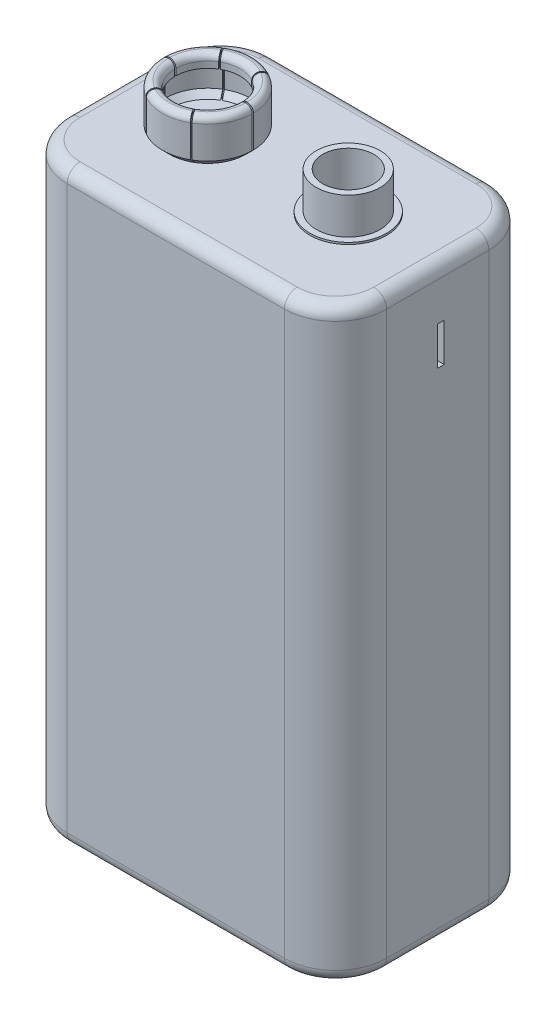
from build123d import *

# Parameters (mm, degrees)
SKETCH2_W           = 25
SKETCH2_H           = 16
BOSS_EXTRUDE1_DEPTH = 46
FILLET1_R           = 4
FILLET2_R           = 1
SKETCH3_R           = 2.5
SKETCH3_R_2         = 2
EXTRUDE_THIN1_DEPTH = 3
SKETCH6_R           = 1
BOSS_EXTRUDE2_DEPTH = 0.75
SKETCH10_W          = 1.5
SKETCH10_H          = 0.1
CUT_EXTRUDE1_DEPTH  = 4.375498081
CIRPATTERN1_COUNT   = 6
SKETCH11_R          = 3
BOSS_EXTRUDE3_DEPTH = 0.15
CUT_EXTRUDE2_DEPTH  = 1
SKETCH13_W          = 0.5
SKETCH13_H          = 3
CUT_EXTRUDE3_DEPTH  = 1


with BuildPart() as part:
    # Sketch2 → Boss-Extrude1 (new body)
    with BuildSketch(Plane(origin=(0, 0, 0), x_dir=(1, 0, 0), z_dir=(0, 1, 0))):
        Rectangle(SKETCH2_W, SKETCH2_H)
    extrude(amount=BOSS_EXTRUDE1_DEPTH)

    # Fillet1
    fillet1_edges = [part.edges().sort_by_distance(p)[0] for p in [
        (12.5, 23, 8),
        (-12.5, 23, 8),
        (-12.5, 23, -8),
        (12.5, 23, -8),
    ]]
    fillet(fillet1_edges, radius=FILLET1_R)

    # Fillet2
    fillet2_edges = [part.edges().sort_by_distance(p)[0] for p in [
        (-12.5, 0, 0),
        (-12.5, 46, 0),
        (12.5, 0, 0),
        (0, 0, 8),
        (0, 0, -8),
        (11.328427125, 0, 6.828427125),
        (11.328427125, 0, -6.828427125),
        (-11.328427125, 0, 6.828427125),
        (-11.328427125, 0, -6.828427125),
        (0, 46, -8),
        (12.5, 46, 0),
        (0, 46, 8),
        (11.328427125, 46, 6.828427125),
        (11.328427125, 46, -6.828427125),
        (-11.328427125, 46, 6.828427125),
        (-11.328427125, 46, -6.828427125),
    ]]
    fillet(fillet2_edges, radius=FILLET2_R)

    # Sketch3 → Extrude-Thin1 (add)
    with BuildSketch(Plane(origin=(0, 46, 0), x_dir=(1, 0, 0), z_dir=(0, 1, 0))):
        with Locations((5.5, 0)):
            Circle(SKETCH3_R)
        with Locations((5.5, 0)):
            Circle(SKETCH3_R_2, mode=Mode.SUBTRACT)
    extrude(amount=EXTRUDE_THIN1_DEPTH)

    # Sketch6 → Boss-Extrude2 (add)
    with BuildSketch(Plane(origin=(0, 46, 0), x_dir=(1, 0, 0), z_dir=(0, 1, 0))):
        with Locations((-5.5, 0)):
            Circle(SKETCH6_R)
        with Locations((5.5, 0)):
            Circle(SKETCH6_R)
    extrude(amount=BOSS_EXTRUDE2_DEPTH)

    # Sketch9 → Revolve-Thin1 (revolve)
    with BuildSketch(Plane.XY):
        with BuildLine():
            Line((-4.5, 46), (-2.5, 46))
            Line((-2.5, 46), (-1.969669914, 46.530330086))
            Line((-1.969669914, 46.530330086), (-1.969669914, 49.030330086))
            ThreePointArc((-1.969669914, 49.030330086), (-2.116202444, 49.381961465), (-2.469074773, 49.525479854))
            ThreePointArc((-2.469074773, 49.525479854), (-2.819198532, 49.380453844), (-2.964224541, 49.030330086))
            Line((-2.964224541, 49.030330086), (-2.964224541, 48.535180318))
            Line((-2.964224541, 48.535180318), (-2.814224541, 48.535180318))
            Line((-2.814224541, 48.535180318), (-2.814224541, 49.030330086))
            ThreePointArc((-2.814224541, 49.030330086), (-2.712905513, 49.274614618), (-2.468433015, 49.375479257))
            ThreePointArc((-2.468433015, 49.375479257), (-2.222041674, 49.27566845), (-2.119669914, 49.030330086))
            Line((-2.119669914, 49.030330086), (-2.119669914, 46.59246212))
            Line((-2.119669914, 46.59246212), (-2.562132034, 46.15))
            Line((-2.562132034, 46.15), (-4.5, 46.15))
            Line((-4.5, 46.15), (-4.5, 46))
        make_face()
    revolve(axis=Axis((-5.5, 46.75, 0), (0, -1, 0)))

    # Sketch10 → Cut-Extrude1 (cut, through all)
    with BuildSketch(Plane(origin=(0, 46.15, 0), x_dir=(1, 0, 0), z_dir=(0, 1, 0))):
        with Locations((-2.469074773, 0)):
            Rectangle(SKETCH10_W, SKETCH10_H)
    cut_extrude1 = extrude(amount=CUT_EXTRUDE1_DEPTH, mode=Mode.SUBTRACT)

    # CirPattern1: Cut-Extrude1 ×6 about axis
    cirpattern1_axis = Axis((-5.5, 0, 0), (0, 1, 0))
    for i in range(1, CIRPATTERN1_COUNT):
        add(cut_extrude1.rotate(cirpattern1_axis, i * 360 / CIRPATTERN1_COUNT), mode=Mode.SUBTRACT)

    # Sketch11 → Boss-Extrude3 (add)
    with BuildSketch(Plane(origin=(0, 46, 0), x_dir=(1, 0, 0), z_dir=(0, 1, 0))):
        with Locations((5.5, 0)):
            Circle(SKETCH11_R)
    extrude(amount=BOSS_EXTRUDE3_DEPTH)

    # Sketch12 → Cut-Extrude2 (cut)
    with BuildSketch(Plane.ZY.offset(12.5)):
        Polygon((-0.5, 40), (-2, 40), (-2, 40.5), (-0.5, 40.5), (-0.5, 42), (0, 42), (0, 40.5), (1.5, 40.5), (1.5, 40), (0, 40), (0, 38.5), (-0.5, 38.5), align=None)
    extrude(amount=-CUT_EXTRUDE2_DEPTH, mode=Mode.SUBTRACT)

    # Sketch13 → Cut-Extrude3 (cut)
    with BuildSketch(Plane(origin=(12.5, 0, 0), x_dir=(0, 0, -1), z_dir=(1, 0, 0))):
        with Locations((0.25, 40.5)):
            Rectangle(SKETCH13_W, SKETCH13_H)
    extrude(amount=-CUT_EXTRUDE3_DEPTH, mode=Mode.SUBTRACT)


solid = part.part
